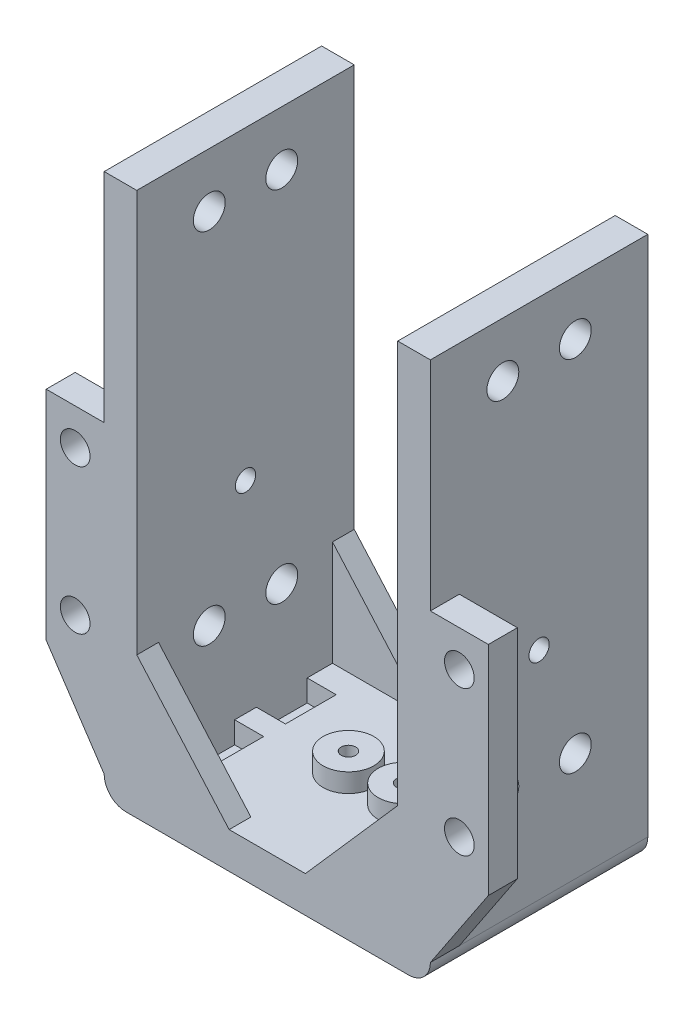
from build123d import *

# Parameters (mm, degrees)
SKETCH1_W           = 45
SKETCH1_H           = 30
SKETCH1_R           = 3.5
BOSS_EXTRUDE1_DEPTH = 5
SKETCH1_4_R         = 3.5
SKETCH1_4_R_2       = 1
BOSS_EXTRUDE2_DEPTH = 7.6
SKETCH2_W           = 4.5
SKETCH2_H           = 30
BOSS_EXTRUDE3_DEPTH = 70
SKETCH3_R           = 1.4
SKETCH3_R_2         = 2.2
CUT_EXTRUDE1_DEPTH  = 4.5
FILLET1_R           = 3
SKETCH6_W           = 4.008200323
SKETCH6_H           = 7
CUT_EXTRUDE3_DEPTH  = 3
BOSS_EXTRUDE4_DEPTH = 3
SKETCH8_R           = 2.05
BOSS_EXTRUDE5_DEPTH = 4


with BuildPart() as part:
    # Sketch1 → Boss-Extrude1 (new body)
    with BuildSketch(Plane(origin=(0, 0, 0), x_dir=(1, 0, 0), z_dir=(0, 1, 0))):
        Rectangle(SKETCH1_W, SKETCH1_H)
        with Locations((-3.8, 0)):
            Circle(SKETCH1_R, mode=Mode.SUBTRACT)
        with Locations((3.8, 0)):
            Circle(SKETCH1_R, mode=Mode.SUBTRACT)
    extrude(amount=BOSS_EXTRUDE1_DEPTH)

    # Sketch1_4 → Boss-Extrude2 (add)
    # profile 1 of 2: a face of its own
    with BuildSketch(Plane(origin=(0, 0, 0), x_dir=(1, 0, 0), z_dir=(0, 1, 0))):
        with Locations((-3.8, 0)):
            Circle(SKETCH1_4_R)
        with Locations((-3.8, 0)):
            Circle(SKETCH1_4_R_2, mode=Mode.SUBTRACT)
    # profile 2 of 2: a face of its own
    with BuildSketch(Plane(origin=(0, 0, 0), x_dir=(1, 0, 0), z_dir=(0, 1, 0))):
        with Locations((3.8, 0)):
            Circle(SKETCH1_4_R)
        with Locations((3.8, 0)):
            Circle(SKETCH1_4_R_2, mode=Mode.SUBTRACT)
    extrude(amount=BOSS_EXTRUDE2_DEPTH)

    # Sketch2 → Boss-Extrude3 (add)
    with BuildSketch(Plane(origin=(0, 5, 0), x_dir=(1, 0, 0), z_dir=(0, 1, 0))):
        with Locations((-20.25, 0)):
            Rectangle(SKETCH2_W, SKETCH2_H)
        with Locations((20.25, 0)):
            Rectangle(SKETCH2_W, SKETCH2_H)
    extrude(amount=BOSS_EXTRUDE3_DEPTH)

    # Sketch3 → Cut-Extrude1 (cut)
    with BuildSketch(Plane.ZY.offset(22.5)):
        with Locations((0, 32.83)):
            Circle(SKETCH3_R)
        with Locations((5, 17.98)):
            Circle(SKETCH3_R_2)
        with Locations((-5, 17.98)):
            Circle(SKETCH3_R_2)
        with Locations((-5, 67.48)):
            Circle(SKETCH3_R_2)
        with Locations((5, 67.48)):
            Circle(SKETCH3_R_2)
    cut_extrude1 = extrude(amount=-CUT_EXTRUDE1_DEPTH, mode=Mode.SUBTRACT)

    # Fillet1
    fillet1_edges = [part.edges().sort_by_distance(p)[0] for p in [
        (22.5, 0, 0),
        (-22.5, 0, 0),
    ]]
    fillet(fillet1_edges, radius=FILLET1_R)

    # Sketch6 → Cut-Extrude3 (cut)
    with BuildSketch(Plane(origin=(0, 5, 0), x_dir=(1, 0, 0), z_dir=(0, 1, 0))):
        with Locations((-15.995899839, 5)):
            Rectangle(SKETCH6_W, SKETCH6_H)
        with Locations((-15.995899839, -5)):
            Rectangle(SKETCH6_W, SKETCH6_H)
    cut_extrude3 = extrude(amount=-CUT_EXTRUDE3_DEPTH, mode=Mode.SUBTRACT)

    # Mirror1: Cut-Extrude1, Cut-Extrude3 across plane
    add(cut_extrude1.mirror(Plane(origin=(0, 0, 0), x_dir=(0, 0, 1), z_dir=(1, 0, 0))), mode=Mode.SUBTRACT)
    add(cut_extrude3.mirror(Plane(origin=(0, 0, 0), x_dir=(0, 0, 1), z_dir=(1, 0, 0))), mode=Mode.SUBTRACT)

    # Sketch7 → Boss-Extrude4 (add)
    with BuildSketch(Plane.XY.offset(15)):
        Polygon((-18, 19.5), (-5.259164302, 5), (-18, 5), align=None)
        Polygon((5.26, 5), (18, 5), (18, 19.5), align=None)
    boss_extrude4 = extrude(amount=-BOSS_EXTRUDE4_DEPTH)

    # Mirror2: Boss-Extrude4 across plane
    add(boss_extrude4.mirror(Plane.XY))

    # Sketch8 → Boss-Extrude5 (add)
    # profile 1 of 2: a face of its own
    with BuildSketch(Plane.XY.offset(15)):
        Polygon((-22.5, 15), (-22.5, 45), (-30.5, 45), (-30.5, 15), (-22.5, 3), align=None)
        with Locations((-26.5, 40)):
            Circle(SKETCH8_R, mode=Mode.SUBTRACT)
        with Locations((-26.5, 20)):
            Circle(SKETCH8_R, mode=Mode.SUBTRACT)
    # profile 2 of 2: a face of its own
    with BuildSketch(Plane.XY.offset(15)):
        Polygon((30.5, 15), (22.5, 3), (22.5, 15), (22.5, 45), (30.5, 45), align=None)
        with Locations((26.5, 20)):
            Circle(SKETCH8_R, mode=Mode.SUBTRACT)
        with Locations((26.5, 40)):
            Circle(SKETCH8_R, mode=Mode.SUBTRACT)
    extrude(amount=-BOSS_EXTRUDE5_DEPTH)


solid = part.part
